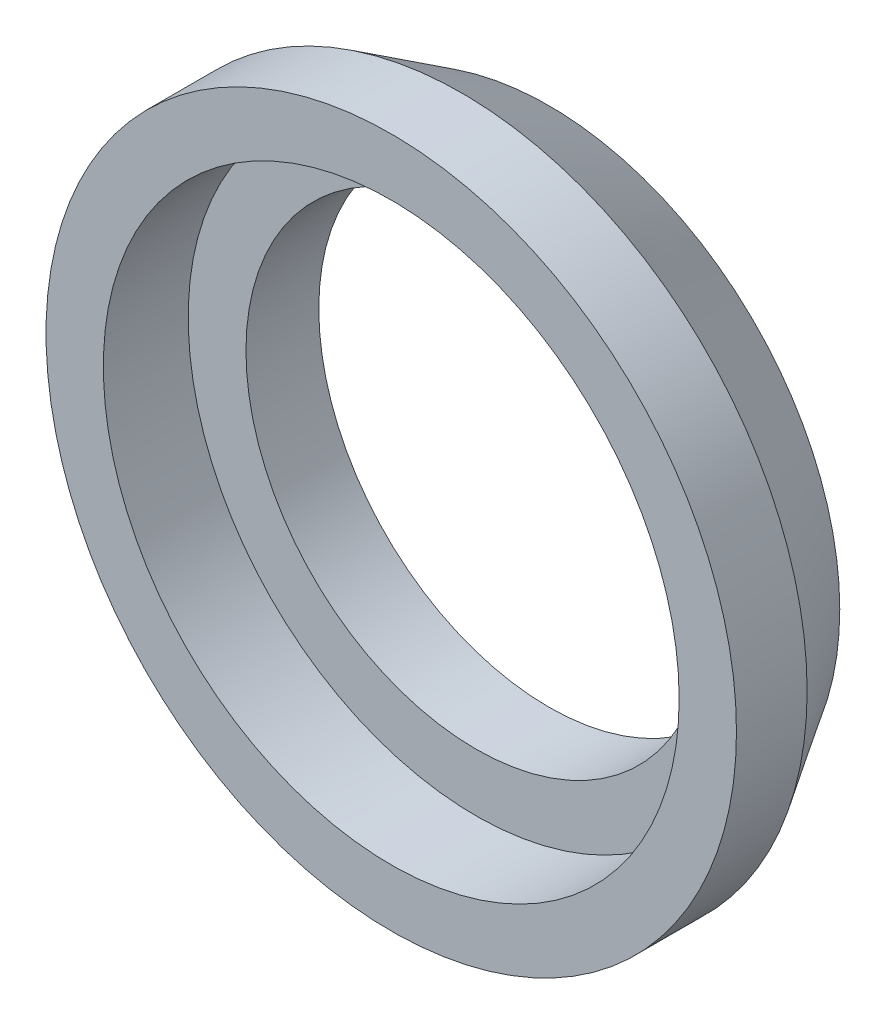
from build123d import *

# Parameters (mm, degrees)
SKETCH1_R             = 9.525
BOSS_EXTRUDE1_DEPTH   = 4.5
SKETCH2_R             = 6.35
CUT_EXTRUDE1_DEPTH    = 10
CHAMFER1_SIZE         = 1.5
CHAMFER1_SIZE2        = 2.400501794
CHAMFER1_PART_2_SIZE  = 1.5
CHAMFER1_PART_2_SIZE2 = 2.400501794
SKETCH3_R             = 7.874
CUT_EXTRUDE2_DEPTH    = 2.011
SKETCH4_R             = 7.94385
CUT_EXTRUDE3_DEPTH    = 4.98
SKETCH5_R             = 24.237402282
CUT_EXTRUDE4_DEPTH    = 5.5
SKETCH6_R             = 11.614236141
CUT_EXTRUDE5_DEPTH    = 0.15


with BuildPart() as part:
    # Sketch1 → Boss-Extrude1 (new body, symmetric)
    with BuildSketch(Plane.XY):
        Circle(SKETCH1_R)
    extrude(amount=BOSS_EXTRUDE1_DEPTH, both=True)

    # Sketch2 → Cut-Extrude1 (cut, through all)
    with BuildSketch(Plane.XY.offset(4.5)):
        Circle(SKETCH2_R)
    extrude(amount=-CUT_EXTRUDE1_DEPTH, mode=Mode.SUBTRACT)

    # Chamfer1
    chamfer1_edges = [part.edges().sort_by_distance(p)[0] for p in [
        (-9.525, 0, -4.5),
    ]]
    chamfer1_side = [part.faces().sort_by_distance(p)[0] for p in [
        (-9.255592316, 0, -4.5),
    ]]
    chamfer(chamfer1_edges, length=CHAMFER1_SIZE, length2=CHAMFER1_SIZE2, reference=chamfer1_side[0])

    # Chamfer1 part 2
    chamfer1_part_2_edges = [part.edges().sort_by_distance(p)[0] for p in [
        (-9.525, 0, 4.5),
    ]]
    chamfer1_part_2_side = [part.faces().sort_by_distance(p)[0] for p in [
        (-9.255592316, 0, 4.5),
    ]]
    chamfer(chamfer1_part_2_edges, length=CHAMFER1_PART_2_SIZE, length2=CHAMFER1_PART_2_SIZE2, reference=chamfer1_part_2_side[0])

    # Sketch3 → Cut-Extrude2 (cut)
    with BuildSketch(Plane.XY.offset(4.5)):
        Circle(SKETCH3_R)
    extrude(amount=-CUT_EXTRUDE2_DEPTH, mode=Mode.SUBTRACT)

    # Sketch4 → Cut-Extrude3 (cut)
    with BuildSketch(Plane.XY.offset(2.489)):
        Circle(SKETCH4_R)
    extrude(amount=-CUT_EXTRUDE3_DEPTH, mode=Mode.SUBTRACT)

    # Sketch5 → Cut-Extrude4 (cut, through all)
    with BuildSketch(Plane.XY):
        Circle(SKETCH5_R)
    extrude(amount=CUT_EXTRUDE4_DEPTH, mode=Mode.SUBTRACT)

    # Sketch6 → Cut-Extrude5 (cut)
    with BuildSketch(Plane.XY):
        Circle(SKETCH6_R)
    extrude(amount=-CUT_EXTRUDE5_DEPTH, mode=Mode.SUBTRACT)


solid = part.part
